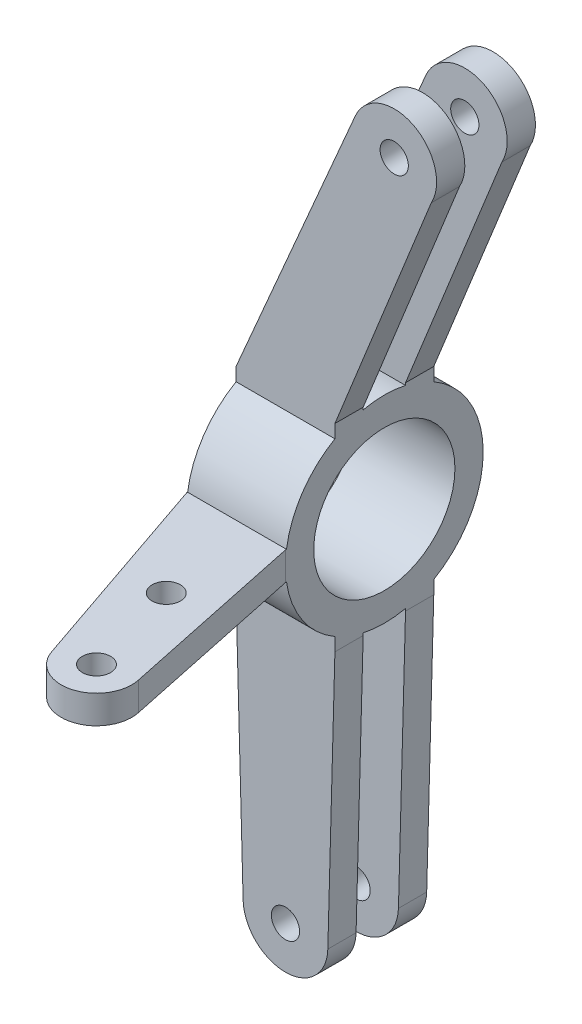
from build123d import *

# Parameters (mm, degrees)
SKETCH1_R             = 35
SKETCH1_R_2           = 25
BOSS_EXTRUDE1_DEPTH   = 17.5
SKETCH5_R             = 5
BOSS_EXTRUDE3_DEPTH   = 10
BOSS_EXTRUDE3_2_DEPTH = 10
SKETCH4_R             = 5
BOSS_EXTRUDE5_DEPTH   = 10
BOSS_EXTRUDE5_2_DEPTH = 10
BOSS_EXTRUDE6_DEPTH   = 35
SKETCH14_R            = 5
BOSS_EXTRUDE12_DEPTH  = 5
BOSS_EXTRUDE13_DEPTH  = 35


with BuildPart() as part:
    # Sketch1 → Boss-Extrude1 (new body, symmetric)
    with BuildSketch(Plane(origin=(0, 0, 0), x_dir=(0, 0, -1), z_dir=(1, 0, 0))):
        Circle(SKETCH1_R)
        Circle(SKETCH1_R_2, mode=Mode.SUBTRACT)
    extrude(amount=BOSS_EXTRUDE1_DEPTH, both=True)



with BuildPart() as body_2:
    # Sketch5 → Boss-Extrude3 (new body)
    with BuildSketch(Plane.XY.offset(-7.5)):
        with BuildLine():
            Line((-17.5, -35), (-14.994489274, -127.40656046))
            ThreePointArc((-14.994489274, -127.40656046), (0, -142), (14.994489274, -127.40656046))
            Line((14.994489274, -127.40656046), (17.5, -35))
            Line((17.5, -35), (-17.5, -35))
        make_face()
        with Locations((0, -127)):
            Circle(SKETCH5_R, mode=Mode.SUBTRACT)
    extrude(amount=-BOSS_EXTRUDE3_DEPTH)


with BuildPart() as body_3:
    # Sketch5 → Boss-Extrude3 2 (new body)
    with BuildSketch(Plane.XY.offset(-7.5)):
        with BuildLine():
            Line((-17.5, 35), (17.5, 35))
            Line((17.5, 35), (51.609186621, 119.709648423))
            ThreePointArc((51.609186621, 119.709648423), (45.122886874, 140.458728374), (24.725687056, 132.938712227))
            Line((24.725687056, 132.938712227), (-17.5, 35))
        make_face()
        with Locations((38.5, 127)):
            Circle(SKETCH5_R, mode=Mode.SUBTRACT)
    extrude(amount=-BOSS_EXTRUDE3_2_DEPTH)


with BuildPart() as body_4:
    # Sketch4 → Boss-Extrude5 (new body)
    with BuildSketch(Plane.XY.offset(7.5)):
        with BuildLine():
            Line((-17.5, -35), (-14.994489274, -127.40656046))
            ThreePointArc((-14.994489274, -127.40656046), (0, -142), (14.994489274, -127.40656046))
            Line((14.994489274, -127.40656046), (17.5, -35))
            Line((17.5, -35), (-17.5, -35))
        make_face()
        with Locations((0, -127)):
            Circle(SKETCH4_R, mode=Mode.SUBTRACT)
    extrude(amount=BOSS_EXTRUDE5_DEPTH)


with BuildPart() as body_5:
    # Sketch4 → Boss-Extrude5 2 (new body)
    with BuildSketch(Plane.XY.offset(7.5)):
        with BuildLine():
            Line((-17.5, 35), (24.725687056, 132.938712227))
            ThreePointArc((24.725687056, 132.938712227), (45.122886874, 140.458728374), (51.609186621, 119.709648423))
            Line((51.609186621, 119.709648423), (17.5, 35))
            Line((17.5, 35), (-17.5, 35))
        make_face()
        with Locations((38.5, 127)):
            Circle(SKETCH4_R, mode=Mode.SUBTRACT)
    extrude(amount=BOSS_EXTRUDE5_2_DEPTH)


with BuildPart() as part_1:
    add(part.part)

    add(body_2.part)  # Boss-Extrude6 merges body 2

    add(body_3.part)  # Boss-Extrude6 merges body 3

    add(body_4.part)  # Boss-Extrude6 merges body 4

    add(body_5.part)  # Boss-Extrude6 merges body 5
    # Sketch7 → Boss-Extrude6 (add)
    with BuildSketch(Plane(origin=(17.5, 0, 0), x_dir=(0, 0, -1), z_dir=(1, 0, 0))):
        with BuildLine():
            Line((-17.5, 35), (-17.5, 30.310889132))
            ThreePointArc((-17.5, 30.310889132), (-12.64934905, 32.634245335), (-7.5, 34.186985828))
            Line((-7.5, 34.186985828), (-7.5, 35))
            Line((-7.5, 35), (-17.5, 35))
        make_face()
        with BuildLine():
            Line((7.5, 35), (7.5, 34.186985828))
            ThreePointArc((7.5, 34.186985828), (12.64934905, 32.634245335), (17.5, 30.310889132))
            Line((17.5, 30.310889132), (17.5, 35))
            Line((17.5, 35), (7.5, 35))
        make_face()
        with BuildLine():
            Line((7.5, -35), (7.5, -34.186985828))
            ThreePointArc((7.5, -34.186985828), (12.64934905, -32.634245335), (17.5, -30.310889132))
            Line((17.5, -30.310889132), (17.5, -35))
            Line((17.5, -35), (7.5, -35))
        make_face()
        with BuildLine():
            Line((-7.5, -35), (-7.5, -34.186985828))
            ThreePointArc((-7.5, -34.186985828), (-12.64934905, -32.634245335), (-17.5, -30.310889132))
            Line((-17.5, -30.310889132), (-17.5, -35))
            Line((-17.5, -35), (-7.5, -35))
        make_face()
    extrude(amount=-BOSS_EXTRUDE6_DEPTH)



with BuildPart() as body_2_2:
    # Sketch14 → Boss-Extrude12 (new body, symmetric)
    with BuildSketch(Plane(origin=(0, 0, 0), x_dir=(1, 0, 0), z_dir=(0, 1, 0))):
        with BuildLine():
            Line((17.5, -35), (31.392771581, -101.005420222))
            ThreePointArc((31.392771581, -101.005420222), (22.476413008, -115.632244571), (7.333133213, -107.624341112))
            Line((7.333133213, -107.624341112), (-17.5, -35))
            Line((-17.5, -35), (17.5, -35))
        make_face()
        with Locations((19.160783232, -103.58)):
            Circle(SKETCH14_R, mode=Mode.SUBTRACT)
        with Locations((9.580391616, -69.29)):
            Circle(SKETCH14_R, mode=Mode.SUBTRACT)
    extrude(amount=BOSS_EXTRUDE12_DEPTH, both=True)


with BuildPart() as part_2:
    add(part_1.part)

    add(body_2_2.part)  # Boss-Extrude13 merges body 2 2
    # Sketch15 → Boss-Extrude13 (add)
    with BuildSketch(Plane(origin=(17.5, 0, 0), x_dir=(0, 0, -1), z_dir=(1, 0, 0))):
        with BuildLine():
            Line((-35, 0), (-35, -5))
            Line((-35, -5), (-34.641016151, -5))
            ThreePointArc((-34.641016151, -5), (-34.91013868, -2.506435188), (-35, 0))
        make_face()
        with BuildLine():
            Line((-35, 5), (-35, 0))
            ThreePointArc((-35, 0), (-34.91013868, 2.506435188), (-34.641016151, 5))
            Line((-34.641016151, 5), (-35, 5))
        make_face()
    extrude(amount=-BOSS_EXTRUDE13_DEPTH)


solid = part_2.part
